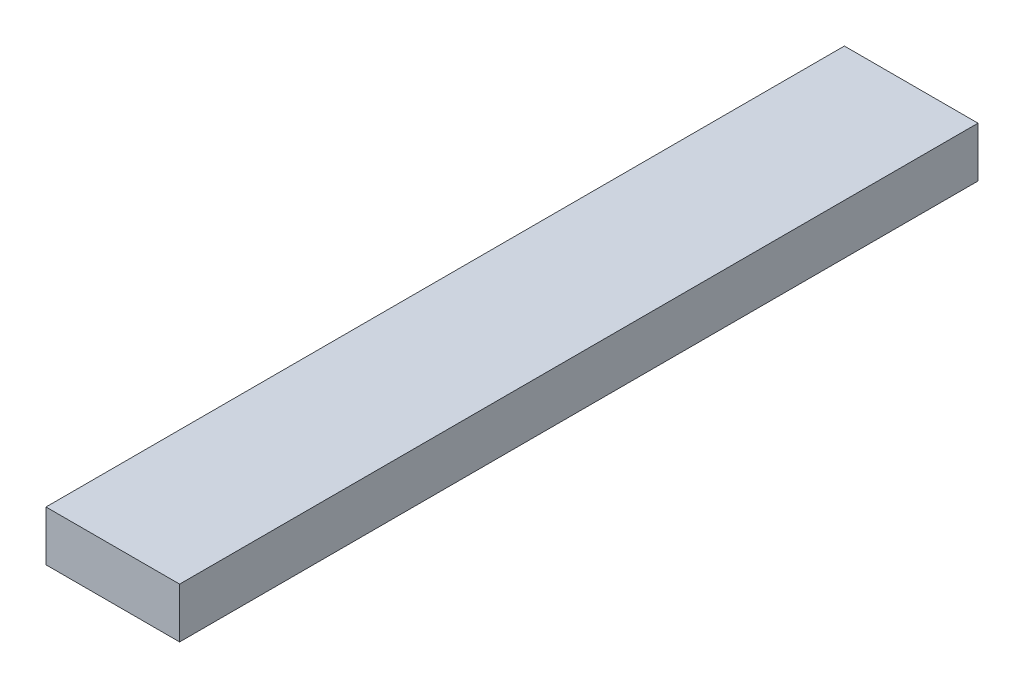
from build123d import *

# Parameters (mm, degrees)
SKETCH_1_W      = 80
SKETCH_1_H      = 478
EXTRUDE_1_DEPTH = 30


with BuildPart() as part:
    # Эскиз1 → Бобышка-Вытянуть1 (new body)
    with BuildSketch(Plane(origin=(0, 0, 0), x_dir=(1, 0, 0), z_dir=(0, 1, 0))):
        with Locations((40, 239)):
            Rectangle(SKETCH_1_W, SKETCH_1_H)
    extrude(amount=EXTRUDE_1_DEPTH)


solid = part.part
